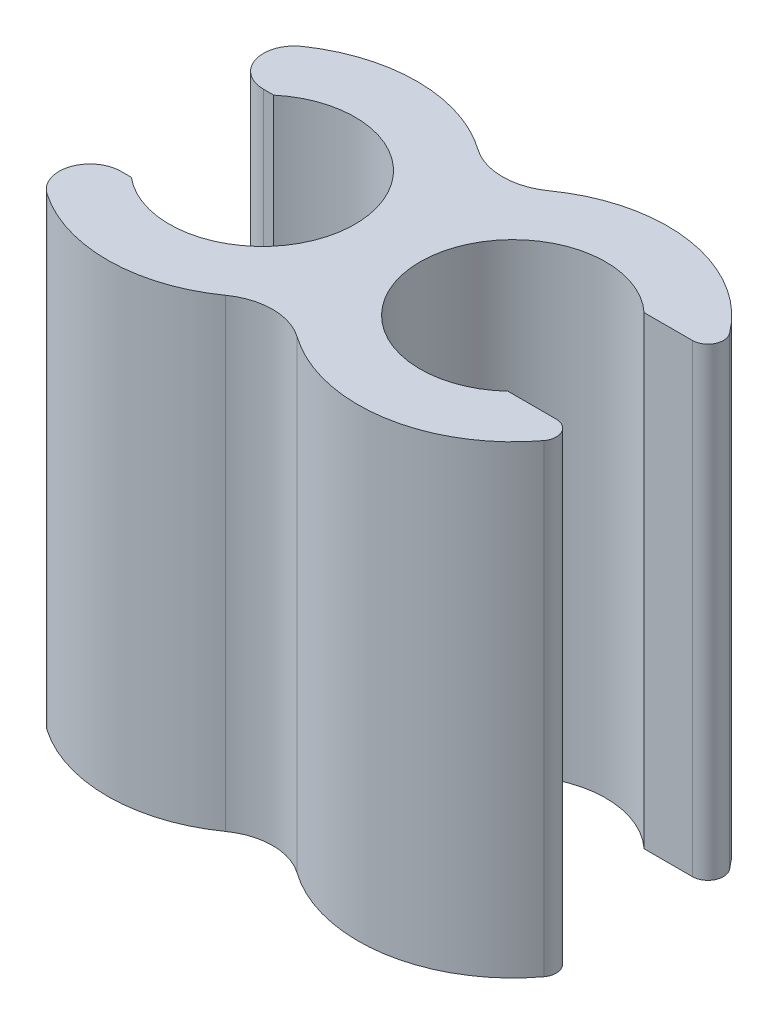
from build123d import *

# Parameters (mm, degrees)
SKETCH1_R           = 5
SKETCH1_R_2         = 3
BOSS_EXTRUDE1_DEPTH = 15
SKETCH2_R           = 5
SKETCH2_R_2         = 3
BOSS_EXTRUDE2_DEPTH = 15
FILLET1_R           = 2
SKETCH3_W           = 7.3092156
SKETCH3_H           = 4.6
CUT_EXTRUDE1_DEPTH  = 15
FILLET2_R           = 1
SKETCH4_W           = 6.886340675
SKETCH4_H           = 4.4
CUT_EXTRUDE2_DEPTH  = 15
FILLET3_R           = 0.5


with BuildPart() as part:
    # Sketch1 → Boss-Extrude1 (new body)
    with BuildSketch(Plane(origin=(0, 0, 0), x_dir=(1, 0, 0), z_dir=(0, 1, 0))):
        Circle(SKETCH1_R)
        Circle(SKETCH1_R_2, mode=Mode.SUBTRACT)
    extrude(amount=BOSS_EXTRUDE1_DEPTH)

    # Sketch2 → Boss-Extrude2 (add)
    with BuildSketch(Plane(origin=(0, 15, 0), x_dir=(1, 0, 0), z_dir=(0, 1, 0))):
        with Locations((8.100044145, -0.002335254)):
            Circle(SKETCH2_R)
        with Locations((8.100044145, -0.002335254)):
            Circle(SKETCH2_R_2, mode=Mode.SUBTRACT)
    extrude(amount=-BOSS_EXTRUDE2_DEPTH)

    # Fillet1
    fillet1_edges = [part.edges().sort_by_distance(p)[0] for p in [
        (4.050867406, 7.5, -2.930950913),
        (4.049176739, 7.5, 2.933286167),
    ]]
    fillet(fillet1_edges, radius=FILLET1_R)

    # Sketch3 → Cut-Extrude1 (cut)
    with BuildSketch(Plane.XZ):
        with Locations((-3.6546078, 0)):
            Rectangle(SKETCH3_W, SKETCH3_H)
    extrude(amount=-CUT_EXTRUDE1_DEPTH, mode=Mode.SUBTRACT)

    # Fillet2
    fillet2_edges = [part.edges().sort_by_distance(p)[0] for p in [
        (-4.439594576, 7.5, 2.3),
        (-4.439594576, 7.5, -2.3),
    ]]
    fillet(fillet2_edges, radius=FILLET2_R)

    # Sketch4 → Cut-Extrude2 (cut)
    with BuildSketch(Plane(origin=(0, 15, 0), x_dir=(1, 0, 0), z_dir=(0, 1, 0))):
        with Locations((11.966816287, -0.002335254)):
            Rectangle(SKETCH4_W, SKETCH4_H)
    extrude(amount=-CUT_EXTRUDE2_DEPTH, mode=Mode.SUBTRACT)

    # Fillet3
    fillet3_edges = [part.edges().sort_by_distance(p)[0] for p in [
        (12.590033009, 7.5, -2.197664746),
        (12.590033009, 7.5, 2.202335254),
    ]]
    fillet(fillet3_edges, radius=FILLET3_R)


solid = part.part
